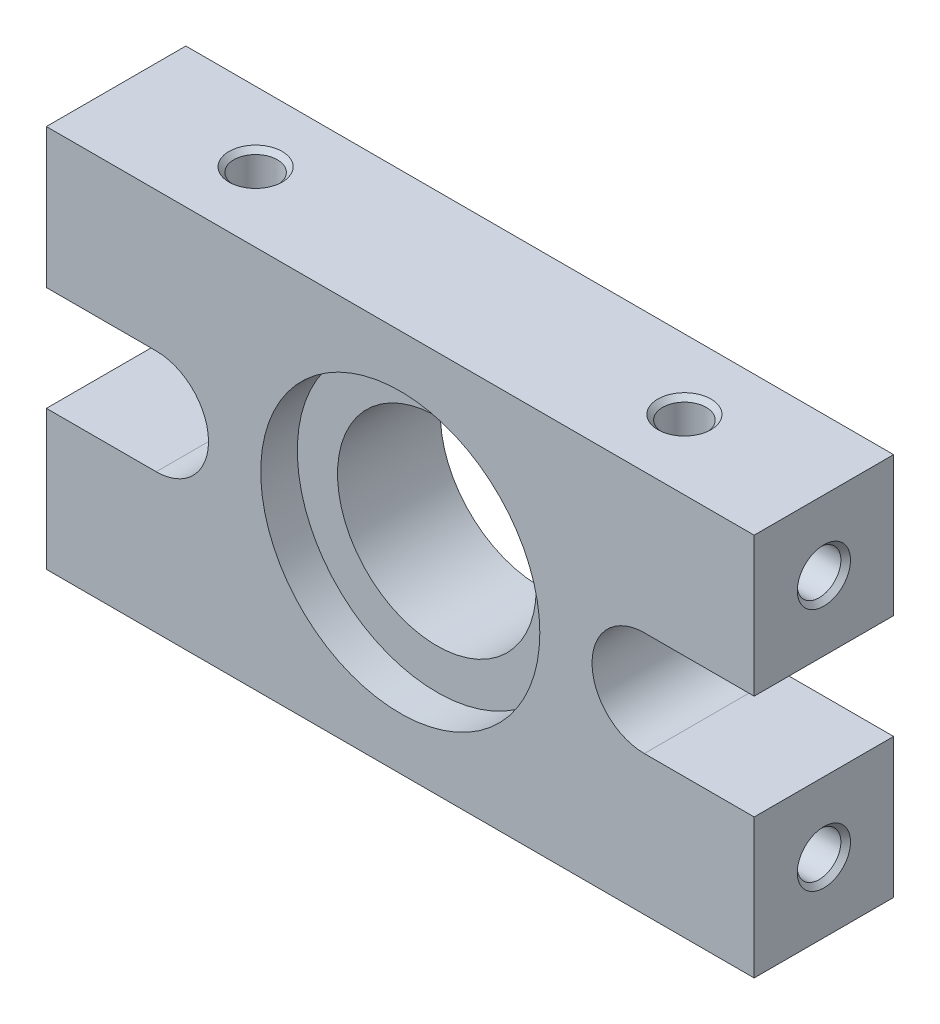
from build123d import *

# Parameters (mm, degrees)
SKETCH1_R           = 5.7
BOSS_EXTRUDE1_DEPTH = 8
SKETCH2_R           = 8.005
CUT_EXTRUDE1_DEPTH  = 2.1


with BuildPart() as part:
    # Sketch1 → Boss-Extrude1 (new body)
    with BuildSketch(Plane.XY):
        with BuildLine():
            Line((0, 14), (0, 22))
            Line((0, 22), (40.6, 22))
            Line((40.6, 22), (40.6, 14))
            Line((40.6, 14), (34.3, 14))
            ThreePointArc((34.3, 14), (31.3, 11), (34.3, 8))
            Line((34.3, 8), (40.6, 8))
            Line((40.6, 8), (40.6, 0))
            Line((40.6, 0), (0, 0))
            Line((0, 0), (0, 8))
            Line((0, 8), (6.3, 8))
            ThreePointArc((6.3, 8), (9.3, 11), (6.3, 14))
            Line((6.3, 14), (0, 14))
        make_face()
        with Locations((20.3, 11)):
            Circle(SKETCH1_R, mode=Mode.SUBTRACT)
    extrude(amount=BOSS_EXTRUDE1_DEPTH)

    # Sketch2 → Cut-Extrude1 (cut)
    with BuildSketch(Plane.XY.offset(8)):
        with Locations((20.3, 11)):
            Circle(SKETCH2_R)
    extrude(amount=-CUT_EXTRUDE1_DEPTH, mode=Mode.SUBTRACT)

    # Sketch3 → M3x0.5 Tapped Hole1 (revolve, cut)
    with BuildSketch(Plane(origin=(32.6, 22, 4), x_dir=(0, 0, 1), z_dir=(1, 0, 0))):
        Polygon((0, 0), (0, 5.751075774), (1.25, 5), (1.25, 0.275), (1.525, 0), align=None)
    m3x0_5_tapped_hole1 = revolve(axis=Axis((32.6, 28.35, 4), (0, -1, 0)), mode=Mode.SUBTRACT)

    # Mirror1: M3x0.5 Tapped Hole1 across plane
    add(m3x0_5_tapped_hole1.mirror(Plane(origin=(20.3, 0, 0), x_dir=(0, 0, 1), z_dir=(1, 0, 0))), mode=Mode.SUBTRACT)

    # Sketch5 → M3x0.5 Tapped Hole2 (revolve, cut)
    with BuildSketch(Plane(origin=(40.6, 18, 4), x_dir=(0, 0, -1), z_dir=(0, 1, 0))):
        Polygon((0, 0), (0, 7.251075774), (1.25, 6.5), (1.25, 0.275), (1.525, 0), align=None)
    m3x0_5_tapped_hole2 = revolve(axis=Axis((46.95, 18, 4), (-1, 0, 0)), mode=Mode.SUBTRACT)

    # Mirror2: M3x0.5 Tapped Hole2 across plane
    add(m3x0_5_tapped_hole2.mirror(Plane(origin=(0, 11, 0), x_dir=(0, 0, 1), z_dir=(0, -1, 0))), mode=Mode.SUBTRACT)

    # Mirror3: M3x0.5 Tapped Hole2 across plane
    add(m3x0_5_tapped_hole2.mirror(Plane(origin=(20.3, 0, 0), x_dir=(0, 0, 1), z_dir=(1, 0, 0))), mode=Mode.SUBTRACT)

    # Mirror3 copy 1 sketch → Mirror3 copy 1 (revolve, cut)
    with BuildSketch(Plane(origin=(0, 4, 4), x_dir=(0, 0, -1), z_dir=(0, -1, 0))):
        Polygon((0, 0), (0, 7.251075774), (1.25, 6.5), (1.25, 0.275), (1.525, 0), align=None)
    revolve(axis=Axis((-6.35, 4, 4), (1, 0, 0)), mode=Mode.SUBTRACT)


solid = part.part
